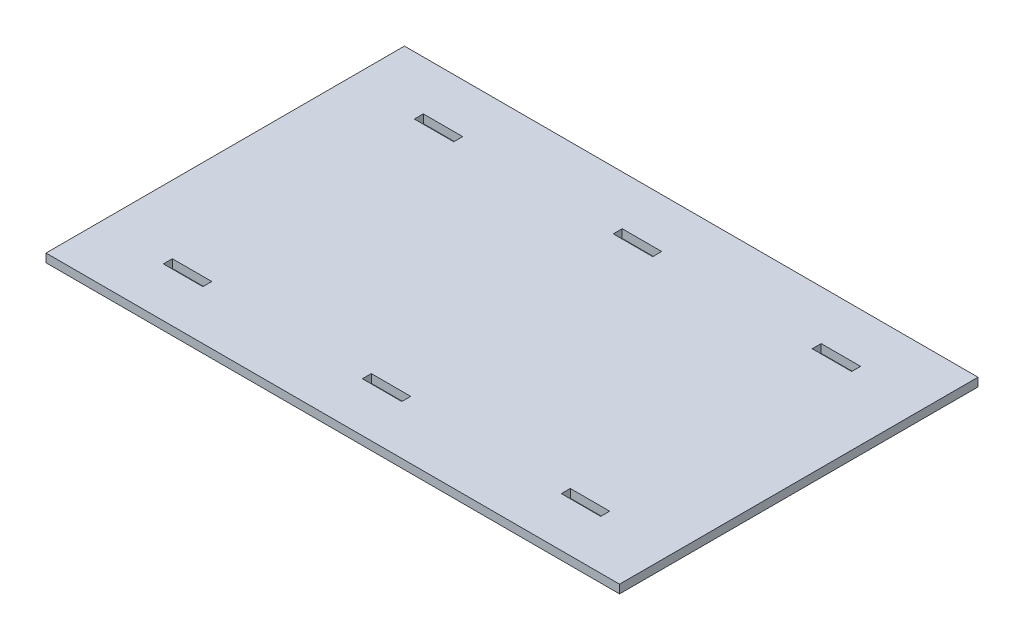
from build123d import *

# Parameters (mm, degrees)
SKETCH1_W      = 203.2
SKETCH1_H      = 127
EXTRUDE1_DEPTH = 2.9972
SKETCH2_W      = 13.97
SKETCH2_H      = 3.175
SLOTS_DEPTH    = 3.9972


with BuildPart() as part:
    # Sketch1 → Extrude1 (new body)
    with BuildSketch(Plane(origin=(0, 0, 0), x_dir=(1, 0, 0), z_dir=(0, 1, 0))):
        Rectangle(SKETCH1_W, SKETCH1_H)
    extrude(amount=EXTRUDE1_DEPTH)

    # Sketch2 → Slots (cut, through all)
    with BuildSketch(Plane(origin=(0, 2.9972, 0), x_dir=(-1, 0, 0), z_dir=(0, 1, 0))):
        with Locations((-70.485, -44.45)):
            Rectangle(SKETCH2_W, SKETCH2_H)
        with Locations((70.485, -44.45)):
            Rectangle(SKETCH2_W, SKETCH2_H)
        with Locations((0, -44.45)):
            Rectangle(SKETCH2_W, SKETCH2_H)
        with Locations((-70.485, 44.45)):
            Rectangle(SKETCH2_W, SKETCH2_H)
        with Locations((0, 44.45)):
            Rectangle(SKETCH2_W, SKETCH2_H)
        with Locations((70.485, 44.45)):
            Rectangle(SKETCH2_W, SKETCH2_H)
    extrude(amount=-SLOTS_DEPTH, mode=Mode.SUBTRACT)


solid = part.part
